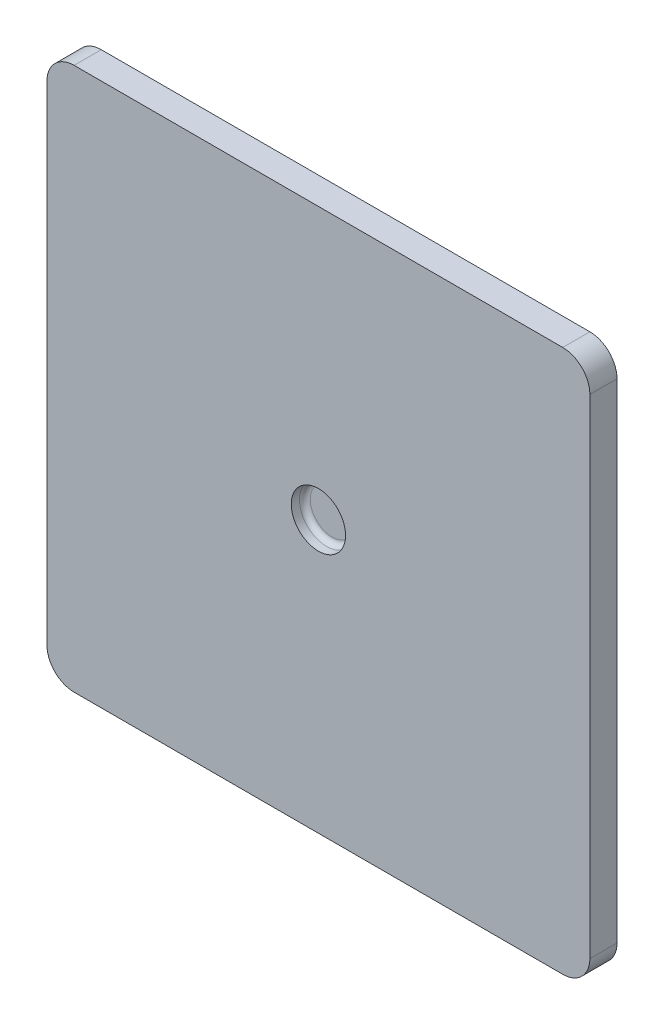
from build123d import *

# Parameters (mm, degrees)
BOSS_EXTRUDE1_DEPTH = 10
SKETCH2_R           = 10
CUT_EXTRUDE2_DEPTH  = 5
FILLET1_R           = 2


with BuildPart() as part:
    # Sketch1 → Boss-Extrude1 (new body)
    with BuildSketch(Plane.XY):
        with BuildLine():
            Line((-90, -100), (90, -100))
            ThreePointArc((90, -100), (97.071067812, -97.071067812), (100, -90))
            Line((100, -90), (100, 90))
            ThreePointArc((100, 90), (97.071067812, 97.071067812), (90, 100))
            Line((90, 100), (-90, 100))
            ThreePointArc((-90, 100), (-97.071067812, 97.071067812), (-100, 90))
            Line((-100, 90), (-100, -90))
            ThreePointArc((-100, -90), (-97.071067812, -97.071067812), (-90, -100))
        make_face()
    extrude(amount=BOSS_EXTRUDE1_DEPTH)

    # Sketch2 → Cut-Extrude2 (cut)
    with BuildSketch(Plane.XY.offset(10)):
        Circle(SKETCH2_R)
    extrude(amount=-CUT_EXTRUDE2_DEPTH, mode=Mode.SUBTRACT)

    # Fillet1
    fillet1_edges = [part.edges().sort_by_distance(p)[0] for p in [
        (-10, 0, 5),
    ]]
    fillet(fillet1_edges, radius=FILLET1_R)


solid = part.part
